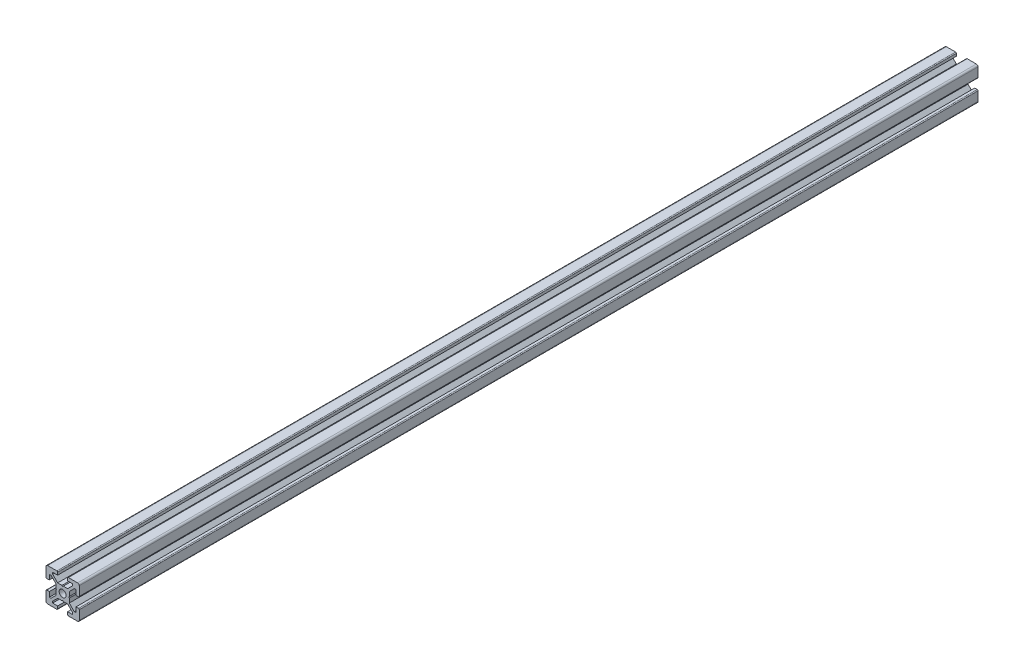
from build123d import *

# Parameters (mm, degrees)
SCHIZZO1_R                   = 2.1
ESTRUSIONE_ESTRUSIONE1_DEPTH = 540


with BuildPart() as part:
    # Schizzo1 → Estrusione-Estrusione1 (new body)
    with BuildSketch(Plane.XY):
        with BuildLine():
            Line((-3.6, 0), (-4, 0.4))
            Line((-4, 0.4), (-4, 3))
            Line((-4, 3), (-7, 6))
            Line((-7, 6), (-8, 6))
            Line((-8, 6), (-8, 3))
            Line((-8, 3), (-9.5, 3))
            ThreePointArc((-9.5, 3), (-9.853553391, 3.146446609), (-10, 3.5))
            Line((-10, 3.5), (-10, 9))
            ThreePointArc((-10, 9), (-9.707106781, 9.707106781), (-9, 10))
            Line((-9, 10), (-3.5, 10))
            ThreePointArc((-3.5, 10), (-3.146446609, 9.853553391), (-3, 9.5))
            Line((-3, 9.5), (-3, 8))
            Line((-3, 8), (-6, 8))
            Line((-6, 8), (-6, 7))
            Line((-6, 7), (-3, 4))
            Line((-3, 4), (-0.4, 4))
            Line((-0.4, 4), (0, 3.6))
            Line((0, 3.6), (0.4, 4))
            Line((0.4, 4), (3, 4))
            Line((3, 4), (6, 7))
            Line((6, 7), (6, 8))
            Line((6, 8), (3, 8))
            Line((3, 8), (3, 9.5))
            ThreePointArc((3, 9.5), (3.146446609, 9.853553391), (3.5, 10))
            Line((3.5, 10), (9, 10))
            ThreePointArc((9, 10), (9.707106781, 9.707106781), (10, 9))
            Line((10, 9), (10, 3.5))
            ThreePointArc((10, 3.5), (9.853553391, 3.146446609), (9.5, 3))
            Line((9.5, 3), (8, 3))
            Line((8, 3), (8, 6))
            Line((8, 6), (7, 6))
            Line((7, 6), (4, 3))
            Line((4, 3), (4, 0.4))
            Line((4, 0.4), (3.6, 0))
            Line((3.6, 0), (4, -0.4))
            Line((4, -0.4), (4, -3))
            Line((4, -3), (7, -6))
            Line((7, -6), (8, -6))
            Line((8, -6), (8, -3))
            Line((8, -3), (9.5, -3))
            ThreePointArc((9.5, -3), (9.853553391, -3.146446609), (10, -3.5))
            Line((10, -3.5), (10, -9))
            ThreePointArc((10, -9), (9.707106781, -9.707106781), (9, -10))
            Line((9, -10), (3.5, -10))
            ThreePointArc((3.5, -10), (3.146446609, -9.853553391), (3, -9.5))
            Line((3, -9.5), (3, -8))
            Line((3, -8), (6, -8))
            Line((6, -8), (6, -7))
            Line((6, -7), (3, -4))
            Line((3, -4), (0.4, -4))
            Line((0.4, -4), (0, -3.6))
            Line((0, -3.6), (-0.4, -4))
            Line((-0.4, -4), (-3, -4))
            Line((-3, -4), (-6, -7))
            Line((-6, -7), (-6, -8))
            Line((-6, -8), (-3, -8))
            Line((-3, -8), (-3, -9.5))
            ThreePointArc((-3, -9.5), (-3.146446609, -9.853553391), (-3.5, -10))
            Line((-3.5, -10), (-9, -10))
            ThreePointArc((-9, -10), (-9.707106781, -9.707106781), (-10, -9))
            Line((-10, -9), (-10, -3.5))
            ThreePointArc((-10, -3.5), (-9.853553391, -3.146446609), (-9.5, -3))
            Line((-9.5, -3), (-8, -3))
            Line((-8, -3), (-8, -6))
            Line((-8, -6), (-7, -6))
            Line((-7, -6), (-4, -3))
            Line((-4, -3), (-4, -0.4))
            Line((-4, -0.4), (-3.6, 0))
        make_face()
        Circle(SCHIZZO1_R, mode=Mode.SUBTRACT)
    extrude(amount=ESTRUSIONE_ESTRUSIONE1_DEPTH)


solid = part.part
